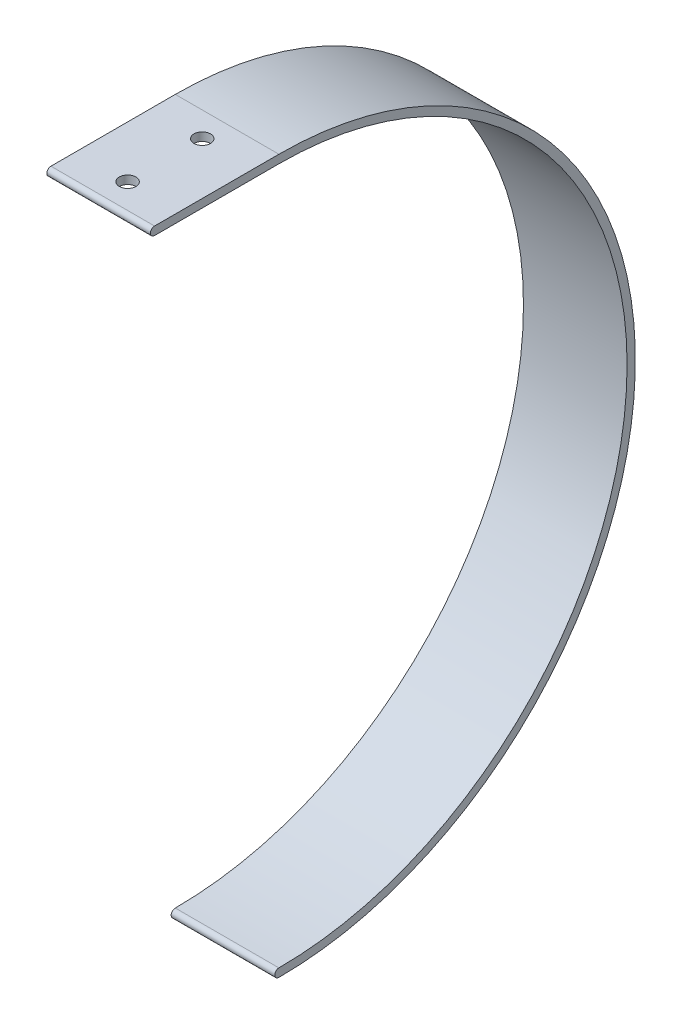
from build123d import *

# Parameters (mm, degrees)
BOSS_EXTRUDE1_DEPTH       = 25
F_4_0MM_DOWEL_HOLE1_D     = 4
F_4_0MM_DOWEL_HOLE1_DEPTH = 17.29
F_4_0MM_DOWEL_HOLE1_TIP   = 1.201721238


with BuildPart() as part:
    # Sketch1 → Boss-Extrude1 (new body)
    with BuildSketch(Plane(origin=(0, 0, 0), x_dir=(0, 0, -1), z_dir=(1, 0, 0))):
        with BuildLine():
            Line((10, 84), (-20, 84))
            ThreePointArc((-20, 84), (-21, 85), (-20, 86))
            Line((-20, 86), (10, 86))
            ThreePointArc((10, 86), (96, 0), (10, -86))
            ThreePointArc((10, -86), (9, -85), (10, -84))
            ThreePointArc((10, -84), (94, 0), (10, 84))
        make_face()
    extrude(amount=BOSS_EXTRUDE1_DEPTH)

    # Ø4.0mm Dowel Hole1
    with Locations(Plane(origin=(0, 86, 0), x_dir=(1, 0, 0), z_dir=(0, 1, 0))):
        with Locations((12.5, -14), (12.5, 4)):
            Hole(F_4_0MM_DOWEL_HOLE1_D / 2, depth=F_4_0MM_DOWEL_HOLE1_DEPTH)
            with Locations((0, 0, -(F_4_0MM_DOWEL_HOLE1_DEPTH + F_4_0MM_DOWEL_HOLE1_TIP / 2))):  # 118° drill point
                Cone(0, F_4_0MM_DOWEL_HOLE1_D / 2, F_4_0MM_DOWEL_HOLE1_TIP, mode=Mode.SUBTRACT)


solid = part.part
